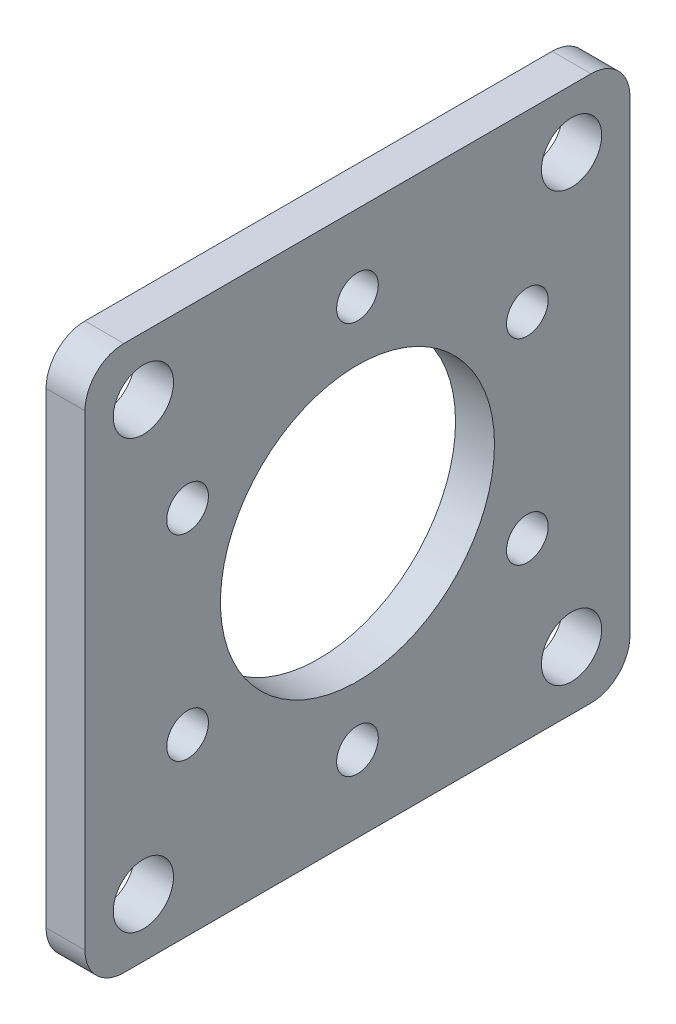
from build123d import *

# Parameters (mm, degrees)
SKETCH1_W                        = 44.45
SKETCH1_H                        = 44.45
SKETCH1_R                        = 11.176
BOSS_EXTRUDE1_DEPTH              = 3.175
F_10_0_1935_DIAMETER_HOLE1_D     = 4.9149
F_10_0_1935_DIAMETER_HOLE1_DEPTH = 3.175
M3_CLEARANCE_HOLE1_D             = 3.4
M3_CLEARANCE_HOLE1_DEPTH         = 3.175
FILLET1_R                        = 3.175


with BuildPart() as part:
    # Sketch1 → Boss-Extrude1 (new body)
    with BuildSketch(Plane(origin=(0, 0, 0), x_dir=(0, 0, -1), z_dir=(1, 0, 0))):
        Rectangle(SKETCH1_W, SKETCH1_H)
        Circle(SKETCH1_R, mode=Mode.SUBTRACT)
    extrude(amount=BOSS_EXTRUDE1_DEPTH)

    # #10 (0.1935) Diameter Hole1
    with Locations(Plane(origin=(3.175, 0, 0), x_dir=(0, 0, -1), z_dir=(1, 0, 0))):
        with Locations((-17.4625, 17.4625), (17.4625, 17.4625), (17.4625, -17.4625), (-17.4625, -17.4625)):
            Hole(F_10_0_1935_DIAMETER_HOLE1_D / 2, depth=F_10_0_1935_DIAMETER_HOLE1_DEPTH)

    # M3 Clearance Hole1
    with Locations(Plane(origin=(3.175, 0, 0), x_dir=(0, 0, -1), z_dir=(1, 0, 0))):
        with Locations((-13.856406461, 8), (0, 16), (13.856406461, 8), (13.856406461, -8), (0, -16), (-13.856406461, -8)):
            Hole(M3_CLEARANCE_HOLE1_D / 2, depth=M3_CLEARANCE_HOLE1_DEPTH)

    # Fillet1
    fillet1_edges = [part.edges().sort_by_distance(p)[0] for p in [
        (1.5875, 22.225, 22.225),
        (1.5875, 22.225, -22.225),
        (1.5875, -22.225, -22.225),
        (1.5875, -22.225, 22.225),
    ]]
    fillet(fillet1_edges, radius=FILLET1_R)


solid = part.part
